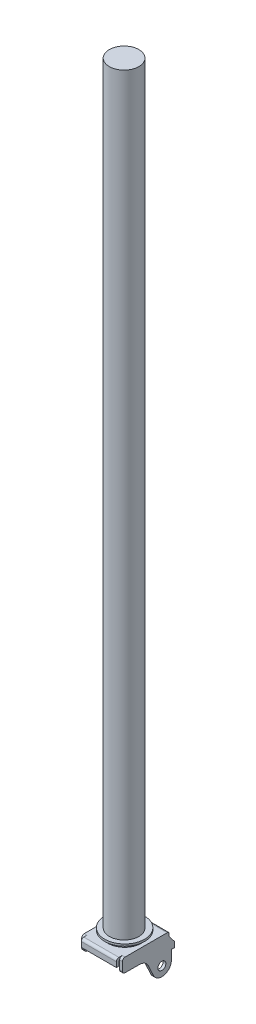
from build123d import *

# Parameters (mm, degrees)
SKETCH1_W           = 35.2425
SKETCH1_H           = 45.085
BOSS_EXTRUDE1_DEPTH = 2.794
SKETCH3_W           = 35.2425
SKETCH3_H           = 7.62
BOSS_EXTRUDE2_DEPTH = 2.794
SKETCH4_W           = 35.2425
SKETCH4_H           = 15.875
BOSS_EXTRUDE3_DEPTH = 2.794
SKETCH5_R           = 3.99415
BOSS_EXTRUDE5_DEPTH = 2.794
SKETCH8_R           = 14.8209
BOSS_EXTRUDE6_DEPTH = 755.65
FILLET1_R           = 2.54


with BuildPart() as part:
    # Sketch1 → Boss-Extrude1 (new body)
    with BuildSketch(Plane(origin=(0, 0, 0), x_dir=(1, 0, 0), z_dir=(0, 1, 0))):
        Rectangle(SKETCH1_W, SKETCH1_H)
    extrude(amount=BOSS_EXTRUDE1_DEPTH)

    # Sketch3 → Boss-Extrude2 (add)
    with BuildSketch(Plane.XY.offset(22.5425)):
        with Locations((0, -1.016)):
            Rectangle(SKETCH3_W, SKETCH3_H)
    extrude(amount=BOSS_EXTRUDE2_DEPTH)

    # Sketch4 → Boss-Extrude3 (add)
    with BuildSketch(Plane(origin=(0, 0, -22.5425), x_dir=(-1, 0, 0), z_dir=(0, 0, -1))):
        with Locations((0, -5.1435)):
            Rectangle(SKETCH4_W, SKETCH4_H)
    extrude(amount=BOSS_EXTRUDE3_DEPTH)

    # Sketch5 → Boss-Extrude5 (add)
    with BuildSketch(Plane.ZY.offset(17.62125)):
        with BuildLine():
            Line((-24.5745, 2.794), (-24.5745, -0.249652205))
            ThreePointArc((-24.5745, -0.249652205), (-24.707295287, -1.060186269), (-25.091795645, -1.785968283))
            Line((-25.091795645, -1.785968283), (-30.3911, -8.763))
            Line((-30.3911, -8.763), (-30.3911, -13.843))
            Line((-30.3911, -13.843), (-26.9875, -13.843))
            Line((-26.9875, -13.843), (-26.9875, -23.3045))
            ThreePointArc((-26.9875, -23.3045), (-19.506235123, -32.571845213), (-8.869629771, -27.213147793))
            Line((-8.869629771, -27.213147793), (-4.188060723, -16.867828085))
            ThreePointArc((-4.188060723, -16.867828085), (-0.439339327, -12.518932794), (5.068277097, -10.8966))
            Line((5.068277097, -10.8966), (19.5707, -10.8966))
            ThreePointArc((19.5707, -10.8966), (21.366751224, -10.152651224), (22.1107, -8.3566))
            Line((22.1107, -8.3566), (22.1107, 0.254))
            ThreePointArc((22.1107, 0.254), (21.366751224, 2.050051224), (19.5707, 2.794))
            Line((19.5707, 2.794), (-24.5745, 2.794))
        make_face()
        with Locations((-17.50695, -23.3045)):
            Circle(SKETCH5_R, mode=Mode.SUBTRACT)
    boss_extrude5 = extrude(amount=BOSS_EXTRUDE5_DEPTH)

    # Mirror1: Boss-Extrude5 across plane
    add(boss_extrude5.mirror(Plane(origin=(0, 0, 0), x_dir=(0, 0, 1), z_dir=(1, 0, 0))))

    # Sketch6 → Revolve1 (revolve)
    with BuildSketch(Plane(origin=(0, 0, 0), x_dir=(0, 0, -1), z_dir=(1, 0, 0))):
        Polygon((0.5588, 2.794), (17.2339, 2.794), (17.2339, 6.1087), (20.5994, 6.1087), (20.5994, 8.1153), (0.5588, 8.1153), align=None)
    revolve(axis=Axis((0, 2.794, -0.5588), (0, 1, 0)))

    # Sketch8 → Boss-Extrude6 (add)
    with BuildSketch(Plane(origin=(0, 8.1153, 0), x_dir=(1, 0, 0), z_dir=(0, 1, 0))):
        Circle(SKETCH8_R)
    extrude(amount=BOSS_EXTRUDE6_DEPTH)

    # Fillet1
    fillet1_edges = [part.edges().sort_by_distance(p)[0] for p in [
        (0, 2.794, -25.3365),
        (0, 2.794, 25.3365),
    ]]
    fillet(fillet1_edges, radius=FILLET1_R)


solid = part.part
